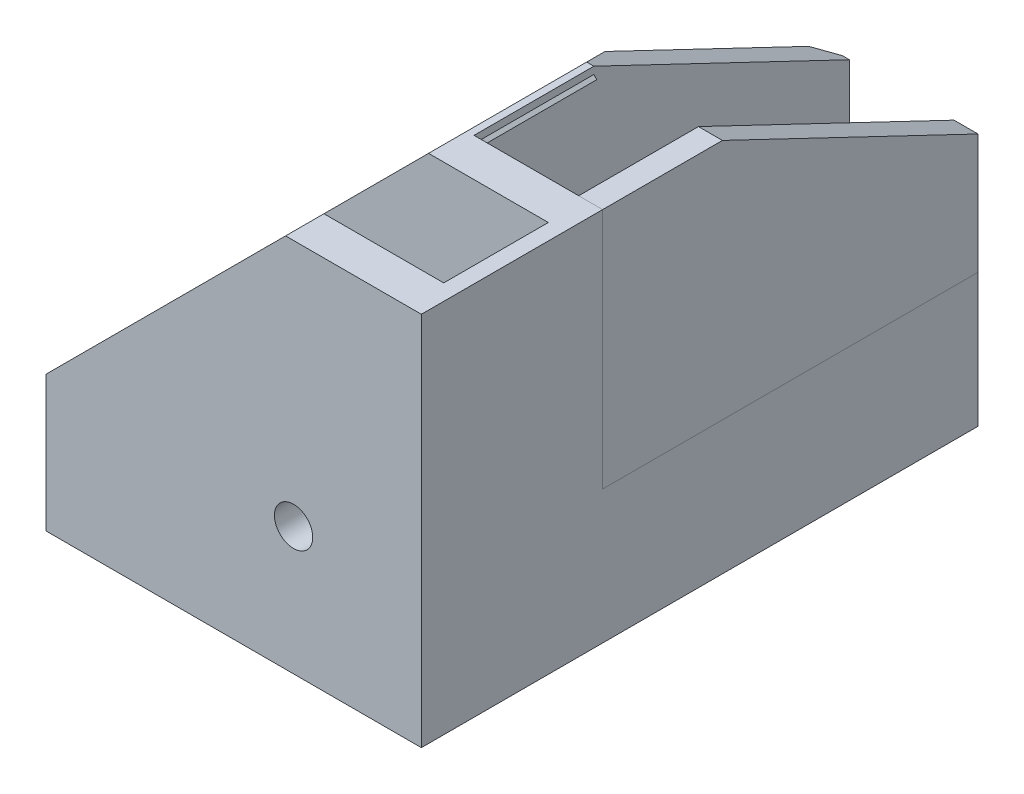
from build123d import *

# Parameters (mm, degrees)
BOSS_EXTRUDE1_DEPTH     = 11.35
CUT_EXTRUDE1_DEPTH      = 6.55
BOSS_EXTRUDE2_DEPTH     = 47
SKETCH5_W               = 3
SKETCH5_H               = 30.3
BOSS_EXTRUDE3_DEPTH     = 47
BOSS_EXTRUDE3_2_DEPTH   = 47
CUT_EXTRUDE2_DEPTH      = 31.3
CUT_EXTRUDE2_DEPTH_BACK = 17.7
CUT_EXTRUDE3_DEPTH      = 47
CUT_EXTRUDE4_DEPTH      = 48
SKETCH8_R               = 2.4
CUT_EXTRUDE5_DEPTH      = 4.8
SKETCH9_W               = 45
SKETCH9_H               = 13.1
CUT_EXTRUDE6_DEPTH      = 2
BOSS_EXTRUDE4_DEPTH     = 1.8


with BuildPart() as part:
    # Sketch1 → Boss-Extrude1 (new body, symmetric)
    with BuildSketch(Plane.XY):
        Polygon((0, 0), (0, 47), (-17, 47), (-47, 17), (-47, 0), align=None)
    extrude(amount=BOSS_EXTRUDE1_DEPTH, both=True)

    # Sketch2 → Cut-Extrude1 (cut, symmetric)
    with BuildSketch(Plane.XY):
        Polygon((-47, 17), (-47, 2), (-2, 2), (-2, 47), (-17, 47), align=None)
    extrude(amount=CUT_EXTRUDE1_DEPTH, both=True, mode=Mode.SUBTRACT)

    # Sketch3 → Boss-Extrude2 (add)
    with BuildSketch(Plane(origin=(0, 0, -11.35), x_dir=(-1, 0, 0), z_dir=(0, 0, -1))):
        Polygon((0, 0), (0, 2), (0, 14.7), (0, 16.7), (47, 16.7), (47, 14.9), (2, 14.9), (2, 1.8), (47, 1.8), (47, 0), align=None)
    extrude(amount=BOSS_EXTRUDE2_DEPTH)

    # Sketch4 → Cut-Extrude2 (cut, two sides)
    with BuildSketch(Plane(origin=(0, 16.7, 0), x_dir=(1, 0, 0), z_dir=(0, 1, 0))) as cut_extrude2_sk:
        Polygon((-17, 58.35), (-47, 28.35), (-47, 58.35), align=None)
    extrude(amount=CUT_EXTRUDE2_DEPTH, mode=Mode.SUBTRACT)
    extrude(cut_extrude2_sk.sketch, amount=-CUT_EXTRUDE2_DEPTH_BACK, mode=Mode.SUBTRACT)

    # Sketch8 → Cut-Extrude5 (cut)
    with BuildSketch(Plane.XY.offset(11.35)):
        with Locations((-16, 16)):
            Circle(SKETCH8_R)
    extrude(amount=-CUT_EXTRUDE5_DEPTH, mode=Mode.SUBTRACT)

    # Sketch9 → Cut-Extrude6 (cut)
    with BuildSketch(Plane(origin=(0, 2, 0), x_dir=(1, 0, 0), z_dir=(0, 1, 0))):
        with Locations((-24.5, 0)):
            Rectangle(SKETCH9_W, SKETCH9_H)
    extrude(amount=-CUT_EXTRUDE6_DEPTH, mode=Mode.SUBTRACT)



with BuildPart() as body_2:
    # Sketch5 → Boss-Extrude3 (new body, through all)
    with BuildSketch(Plane(origin=(0, 0, -11.35), x_dir=(-1, 0, 0), z_dir=(0, 0, -1))):
        with Locations((1.5, 31.85)):
            Rectangle(SKETCH5_W, SKETCH5_H)
    extrude(amount=BOSS_EXTRUDE3_DEPTH)


with BuildPart() as body_3:
    # Sketch5 → Boss-Extrude3 2 (new body, through all)
    with BuildSketch(Plane(origin=(0, 0, -11.35), x_dir=(-1, 0, 0), z_dir=(0, 0, -1))):
        Polygon((16.1, 47), (16.1, 16.7), (19.1, 16.7), (19.1, 44.9), (17, 47), align=None)
    extrude(amount=BOSS_EXTRUDE3_2_DEPTH)

    # Sketch6 → Cut-Extrude3 (cut)
    with BuildSketch(Plane.XZ.offset(-16.7)):
        Polygon((-17, -58.35), (-18.7, -56.65), (-19.1, -56.25), (-19.1, -58.35), (-18.7, -58.35), align=None)
    extrude(amount=-CUT_EXTRUDE3_DEPTH, mode=Mode.SUBTRACT)


with BuildPart() as cut_extrude4_tool:
    # Sketch7 → Cut-Extrude4 (new body, through all)
    with BuildSketch(Plane(origin=(0, 0, 0), x_dir=(0, 0, -1), z_dir=(1, 0, 0))):
        Polygon((58.35, 31.7), (26.35, 47), (58.35, 47), align=None)
    extrude(amount=-CUT_EXTRUDE4_DEPTH)


with BuildPart() as body_2_1:
    add(body_2.part)

    # Cut-Extrude4: cut by cut_extrude4_tool
    add(cut_extrude4_tool.part, mode=Mode.SUBTRACT)


with BuildPart() as body_3_1:
    add(body_3.part)

    # Cut-Extrude4: cut by cut_extrude4_tool
    add(cut_extrude4_tool.part, mode=Mode.SUBTRACT)


with BuildPart() as part_1:
    add(part.part)

    add(body_3_1.part)  # Boss-Extrude4 merges body 3
    # Sketch10 → Boss-Extrude4 (add)
    with BuildSketch(Plane(origin=(-32, 32, 0), x_dir=(0, 0, 1), z_dir=(-0.707106781, 0.707106781, 0))):
        Polygon((-11.35, -21.42533547), (-6.55, -21.42533547), (-6.55, 21.213203436), (-26.35, 21.213203436), (-26.35, -21.42533547), align=None)
    extrude(amount=-BOSS_EXTRUDE4_DEPTH)


solid = Compound([body_2_1.part, part_1.part])
